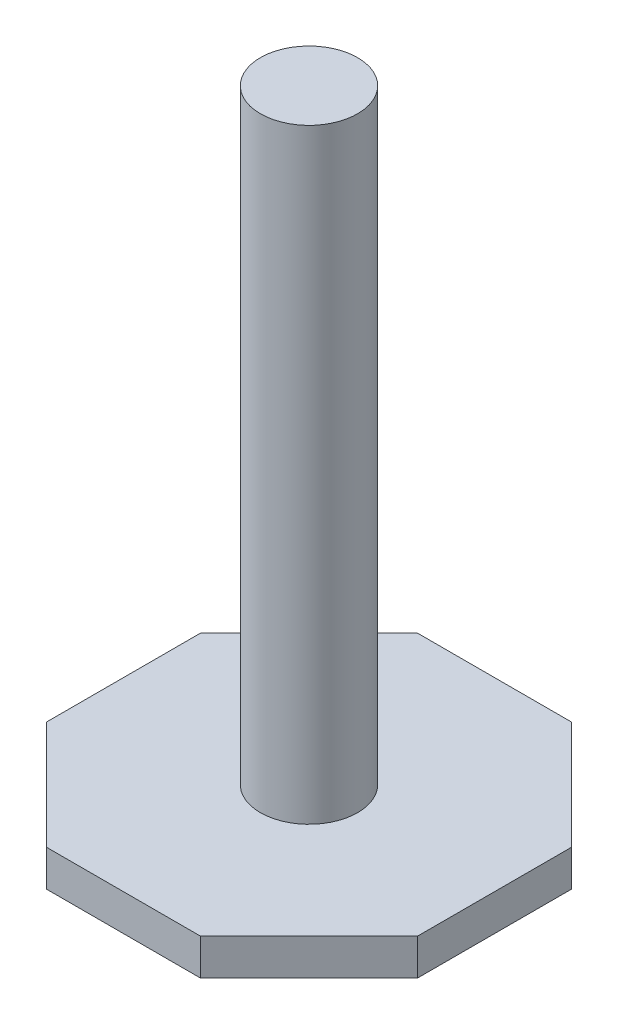
from build123d import *

# Parameters (mm, degrees)
SKETCH_1_R          = 4.015
EXTRUDE_1_DEPTH     = 50
EXTRUDE_2_DEPTH     = 3
CUT_EXTRUDE_1_DEPTH = 1


with BuildPart() as part:
    # 스케치1 → 보스-돌출1 (new body)
    with BuildSketch(Plane(origin=(0, 0, 0), x_dir=(1, 0, 0), z_dir=(0, 1, 0))):
        Circle(SKETCH_1_R)
    extrude(amount=EXTRUDE_1_DEPTH)

    # 스케치2 → 보스-돌출2 (add)
    with BuildSketch(Plane.XZ):
        Polygon((6.345806764, -15.320132754), (15.320132754, -6.345806764), (15.320132754, 6.345806764), (6.345806764, 15.320132754), (-6.345806764, 15.320132754), (-15.320132754, 6.345806764), (-15.320132754, -6.345806764), (-6.345806764, -15.320132754), align=None)
    extrude(amount=EXTRUDE_2_DEPTH)

    # 스케치3 → 컷-돌출1 (cut)
    with BuildSketch(Plane.XZ.offset(3)):
        Polygon((-14.320132754, -5.931593202), (-5.931593202, -14.320132754), (5.931593202, -14.320132754), (14.320132754, -5.931593202), (14.320132754, 5.931593202), (5.931593202, 14.320132754), (-5.931593202, 14.320132754), (-14.320132754, 5.931593202), align=None)
        Polygon((-5.517379639, -13.320132754), (5.517379639, -13.320132754), (13.320132754, -5.517379639), (13.320132754, 5.517379639), (5.517379639, 13.320132754), (-5.517379639, 13.320132754), (-13.320132754, 5.517379639), (-13.320132754, -5.517379639), align=None, mode=Mode.SUBTRACT)
    extrude(amount=-CUT_EXTRUDE_1_DEPTH, mode=Mode.SUBTRACT)


solid = part.part
